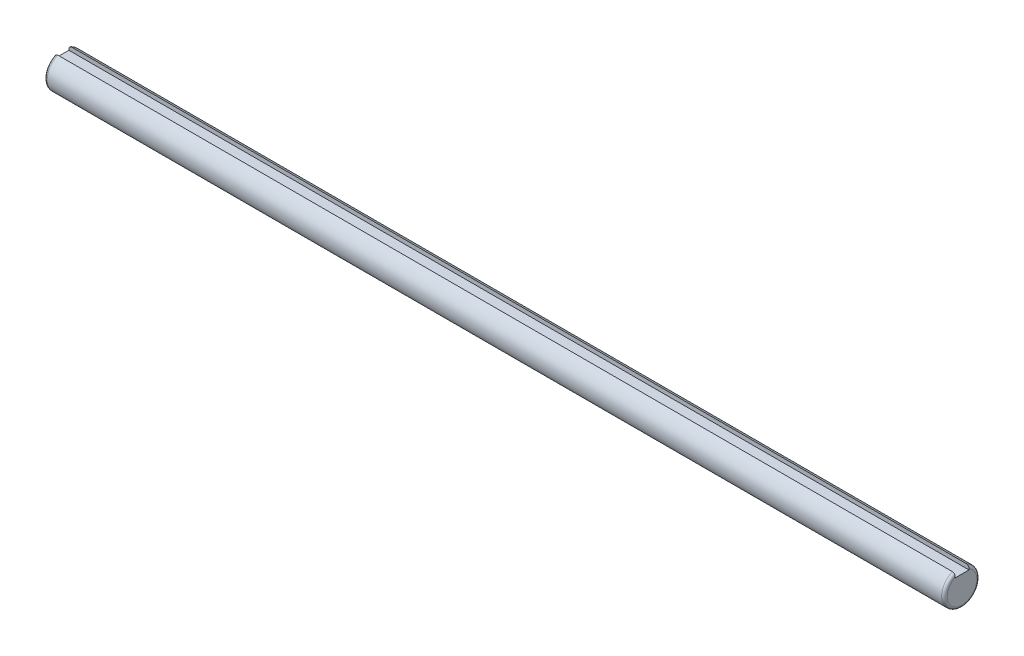
from build123d import *

# Parameters (mm, degrees)
BOSS_EXTRUDE1_DEPTH = 325
FILLET1_R           = 1


with BuildPart() as part:
    # Sketch2 → Boss-Extrude1 (new body)
    with BuildSketch(Plane(origin=(0, 0, 0), x_dir=(0, 0, -1), z_dir=(1, 0, 0))):
        with BuildLine():
            Line((2.5, 5.837165408), (2.5, 4.35))
            Line((2.5, 4.35), (-2.5, 4.35))
            Line((-2.5, 4.35), (-2.5, 5.837165408))
            ThreePointArc((-2.5, 5.837165408), (0, -6.35), (2.5, 5.837165408))
        make_face()
    extrude(amount=BOSS_EXTRUDE1_DEPTH)

    # Fillet1
    fillet1_edges = [part.edges().sort_by_distance(p)[0] for p in [
        (0, -6.35, 0),
        (325, -6.35, 0),
    ]]
    fillet(fillet1_edges, radius=FILLET1_R)


solid = part.part
